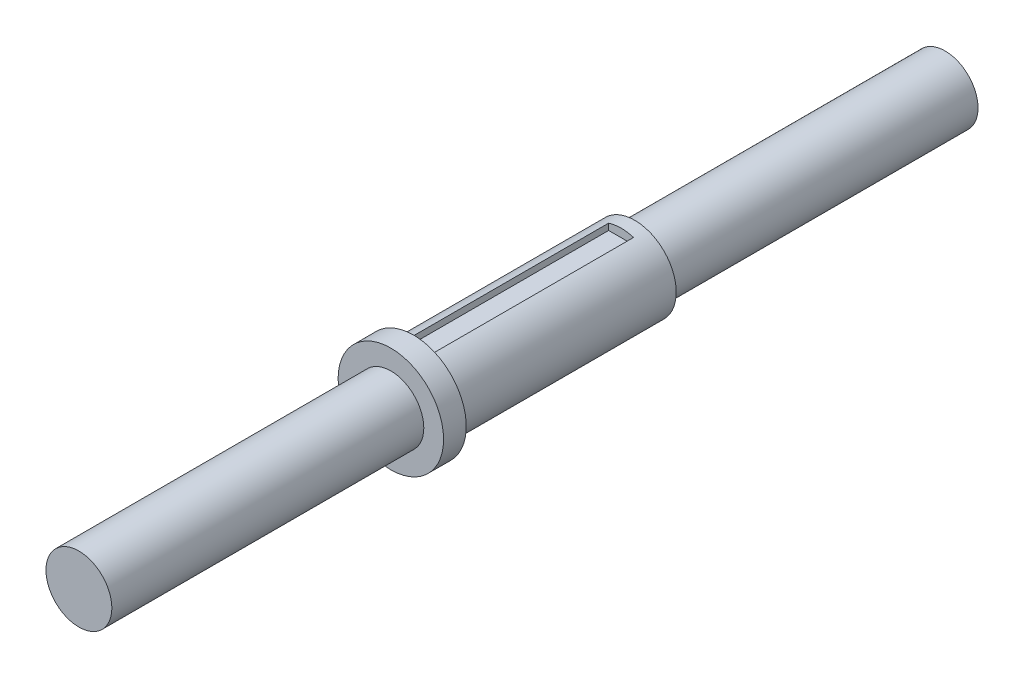
from build123d import *

# Parameters (mm, degrees)
SKETCH1_R           = 6.35
BOSS_EXTRUDE1_DEPTH = 160.3
SKETCH3_OUTSIDE_W   = 46.96
SKETCH3_OUTSIDE_H   = 46.96
SKETCH3_OUTSIDE_R   = 5
CUT_EXTRUDE2_DEPTH  = 120
SKETCH4_OUTSIDE_W   = 46.96
SKETCH4_OUTSIDE_H   = 46.96
SKETCH4_OUTSIDE_R   = 3.96875
CUT_EXTRUDE3_DEPTH  = 37.57
SKETCH5_OUTSIDE_W   = 46.96
SKETCH5_OUTSIDE_H   = 46.96
SKETCH5_OUTSIDE_R   = 3.97
CUT_EXTRUDE4_DEPTH  = 93.36
SKETCH9_W           = 3
SKETCH9_H           = 25
CUT_EXTRUDE6_DEPTH  = 1
SKETCH11_W          = 3.767354336
SKETCH11_H          = 25
CUT_EXTRUDE7_DEPTH  = 1
SKETCH12_R          = 15.914705016
CUT_EXTRUDE8_DEPTH  = 55.98


with BuildPart() as part:
    # Sketch1 → Boss-Extrude1 (new body)
    with BuildSketch(Plane.XY):
        Circle(SKETCH1_R)
    extrude(amount=BOSS_EXTRUDE1_DEPTH)

    # Sketch3 outside → Cut-Extrude2 (cut)
    with BuildSketch(Plane(origin=(0, 0, 0), x_dir=(-1, 0, 0), z_dir=(0, 0, -1))):
        Rectangle(SKETCH3_OUTSIDE_W, SKETCH3_OUTSIDE_H)
        Circle(SKETCH3_OUTSIDE_R, mode=Mode.SUBTRACT)
    extrude(amount=-CUT_EXTRUDE2_DEPTH, mode=Mode.SUBTRACT)

    # Sketch4 outside → Cut-Extrude3 (cut)
    with BuildSketch(Plane.XY.offset(160.3)):
        Rectangle(SKETCH4_OUTSIDE_W, SKETCH4_OUTSIDE_H)
        Circle(SKETCH4_OUTSIDE_R, mode=Mode.SUBTRACT)
    extrude(amount=-CUT_EXTRUDE3_DEPTH, mode=Mode.SUBTRACT)

    # Sketch5 outside → Cut-Extrude4 (cut)
    with BuildSketch(Plane(origin=(0, 0, 0), x_dir=(-1, 0, 0), z_dir=(0, 0, -1))):
        Rectangle(SKETCH5_OUTSIDE_W, SKETCH5_OUTSIDE_H)
        Circle(SKETCH5_OUTSIDE_R, mode=Mode.SUBTRACT)
    extrude(amount=-CUT_EXTRUDE4_DEPTH, mode=Mode.SUBTRACT)

    # Sketch9 → Cut-Extrude6 (cut)
    with BuildSketch(Plane(origin=(0, 5, 0), x_dir=(1, 0, 0), z_dir=(0, 1, 0))):
        with Locations((0, -107.5)):
            Rectangle(SKETCH9_W, SKETCH9_H)
    extrude(amount=-CUT_EXTRUDE6_DEPTH, mode=Mode.SUBTRACT)

    # Sketch11 → Cut-Extrude7 (cut)
    with BuildSketch(Plane(origin=(0, -5, 0), x_dir=(-1, 0, 0), z_dir=(0, -1, 0))):
        with Locations((0, -107.520343873)):
            Rectangle(SKETCH11_W, SKETCH11_H)
    extrude(amount=-CUT_EXTRUDE7_DEPTH, mode=Mode.SUBTRACT)

    # Sketch12 → Cut-Extrude8 (cut)
    with BuildSketch(Plane(origin=(0, 0, 0), x_dir=(-1, 0, 0), z_dir=(0, 0, -1))):
        Circle(SKETCH12_R)
    extrude(amount=-CUT_EXTRUDE8_DEPTH, mode=Mode.SUBTRACT)


solid = part.part
